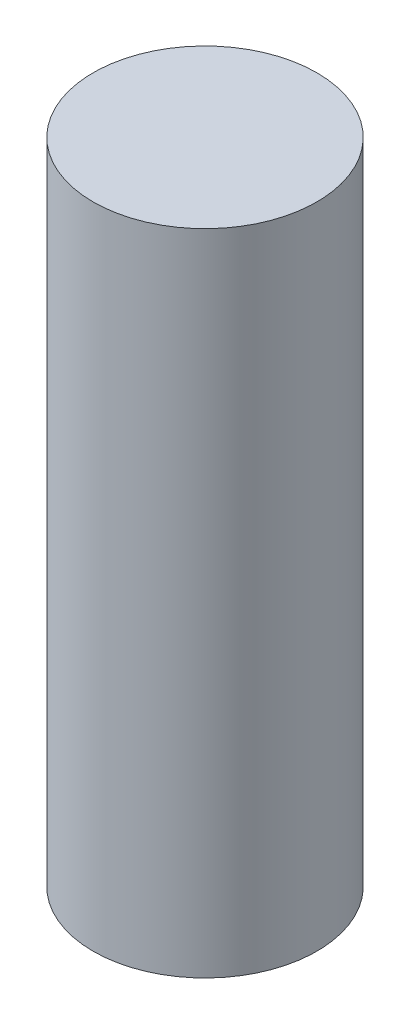
from build123d import *

# Parameters (mm, degrees)
CROQUIS1_R              = 2.5
SALIENTE_EXTRUIR1_DEPTH = 14.5


with BuildPart() as part:
    # Croquis1 → Saliente-Extruir1 (new body)
    with BuildSketch(Plane(origin=(0, 0, 0), x_dir=(1, 0, 0), z_dir=(0, 1, 0))):
        Circle(CROQUIS1_R)
    extrude(amount=SALIENTE_EXTRUIR1_DEPTH)


solid = part.part
